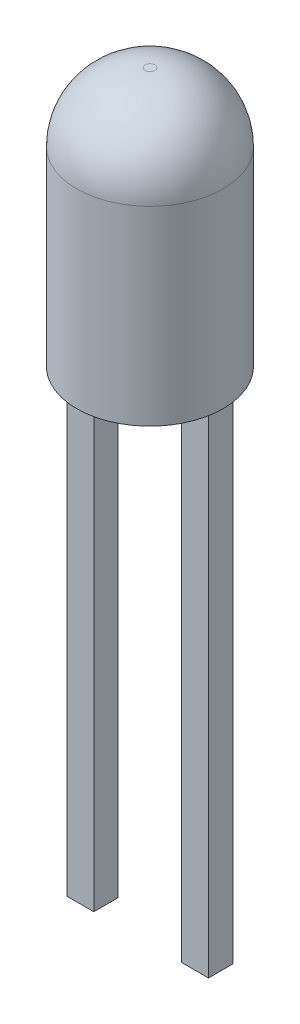
from build123d import *

# Parameters (mm, degrees)
SKETCH2_R                  = 1.5
BOSS_EXTRUDE1_DEPTH        = 5.3
FILLET1_R                  = 1.4
BOSS_EXTRUDE2_DEPTH        = 0.25
BOSS_EXTRUDE2_DEPTH_BACK   = 0.25
BOSS_EXTRUDE2_2_DEPTH      = 0.25
BOSS_EXTRUDE2_2_DEPTH_BACK = 0.25
SKETCH4_W                  = 0.55
SKETCH4_H                  = 0.5
BOSS_EXTRUDE3_DEPTH        = 10
BOSS_EXTRUDE3_2_DEPTH      = 10


with BuildPart() as part:
    # Sketch2 → Boss-Extrude1 (new body)
    with BuildSketch(Plane(origin=(0, 0, 0), x_dir=(1, 0, 0), z_dir=(0, 1, 0))):
        Circle(SKETCH2_R)
    extrude(amount=BOSS_EXTRUDE1_DEPTH)

    # Fillet1
    fillet1_edges = [part.edges().sort_by_distance(p)[0] for p in [
        (-1.5, 5.3, 0),
    ]]
    fillet(fillet1_edges, radius=FILLET1_R)


with BuildPart() as body_2:
    # Sketch3 → Boss-Extrude2 (new, two sides: drawn at the far end of the back side and taken through both)
    with BuildSketch(Plane.XY.offset(-BOSS_EXTRUDE2_DEPTH_BACK)):
        Polygon((-1.45, 2.6), (-1.45, 0), (-0.9, 0), (-0.9, 0.6), (-0.624114196, 0.6), (-0.624114196, 0.82503781), (-1.225355096, 2.6), align=None)
    extrude(amount=BOSS_EXTRUDE2_DEPTH + BOSS_EXTRUDE2_DEPTH_BACK)


with BuildPart() as body_3:
    # Sketch3 → Boss-Extrude2 2 (new, two sides: drawn at the far end of the back side and taken through both)
    with BuildSketch(Plane.XY.offset(-BOSS_EXTRUDE2_2_DEPTH_BACK)):
        Polygon((1.45, 2.6), (-0.872452828, 2.6), (0.496677266, 0.6), (0.9, 0.6), (0.9, 0), (1.45, 0), align=None)
    extrude(amount=BOSS_EXTRUDE2_2_DEPTH + BOSS_EXTRUDE2_2_DEPTH_BACK)


with BuildPart() as body_4:
    # Sketch4 → Boss-Extrude3 (new body)
    with BuildSketch(Plane(origin=(0, 0, 0), x_dir=(-1, 0, 0), z_dir=(0, -1, 0))):
        with Locations((1.175, 0)):
            Rectangle(SKETCH4_W, SKETCH4_H)
    extrude(amount=BOSS_EXTRUDE3_DEPTH)


with BuildPart() as body_5:
    # Sketch4 → Boss-Extrude3 2 (new body)
    with BuildSketch(Plane(origin=(0, 0, 0), x_dir=(-1, 0, 0), z_dir=(0, -1, 0))):
        with Locations((-1.175, 0)):
            Rectangle(SKETCH4_W, SKETCH4_H)
    extrude(amount=BOSS_EXTRUDE3_2_DEPTH)


solid = Compound([part.part, body_2.part, body_3.part, body_4.part, body_5.part])
